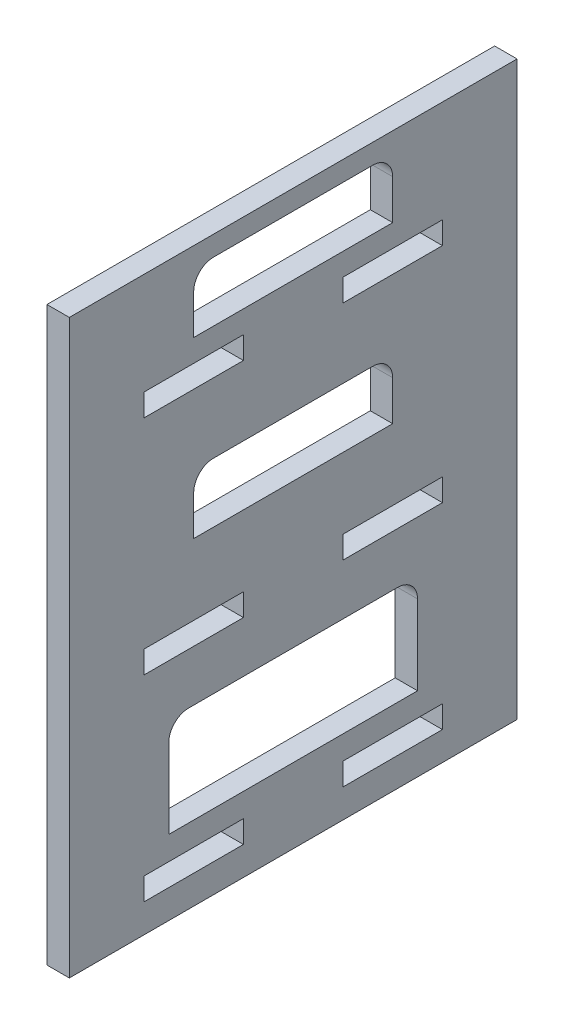
from build123d import *

# Parameters (mm, degrees)
SKETCH1_W           = 40
SKETCH1_H           = 12
SKETCH1_W_2         = 50
SKETCH1_H_2         = 20
SKETCH1_W_3         = 20
SKETCH1_H_3         = 4.5
BOSS_EXTRUDE1_DEPTH = 4.5
FILLET1_R           = 4


with BuildPart() as part:
    # Sketch1 → Boss-Extrude1 (new body)
    with BuildSketch(Plane(origin=(0, 0, 0), x_dir=(0, 0, -1), z_dir=(1, 0, 0))):
        Polygon((0, 0), (0, 5), (0, 45), (0, 50), (0, 90), (0, 95), (0, 115), (90, 115), (90, 45), (90, 5), (90, 0), align=None)
        with Locations((45, 105)):
            Rectangle(SKETCH1_W, SKETCH1_H, mode=Mode.SUBTRACT)
        with Locations((45, 70)):
            Rectangle(SKETCH1_W, SKETCH1_H, mode=Mode.SUBTRACT)
        with Locations((45, 25)):
            Rectangle(SKETCH1_W_2, SKETCH1_H_2, mode=Mode.SUBTRACT)
        with Locations((65, 92.25)):
            Rectangle(SKETCH1_W_3, SKETCH1_H_3, mode=Mode.SUBTRACT)
        with Locations((25, 92.25)):
            Rectangle(SKETCH1_W_3, SKETCH1_H_3, mode=Mode.SUBTRACT)
        with Locations((65, 47.5)):
            Rectangle(SKETCH1_W_3, SKETCH1_H_3, mode=Mode.SUBTRACT)
        with Locations((25, 47.5)):
            Rectangle(SKETCH1_W_3, SKETCH1_H_3, mode=Mode.SUBTRACT)
        with Locations((65, 8)):
            Rectangle(SKETCH1_W_3, SKETCH1_H_3, mode=Mode.SUBTRACT)
        with Locations((25, 8)):
            Rectangle(SKETCH1_W_3, SKETCH1_H_3, mode=Mode.SUBTRACT)
    extrude(amount=BOSS_EXTRUDE1_DEPTH)

    # Fillet1
    fillet1_edges = [part.edges().sort_by_distance(p)[0] for p in [
        (2.25, 76, -65),
        (2.25, 76, -25),
        (2.25, 35, -70),
        (2.25, 35, -20),
        (2.25, 111, -65),
        (2.25, 111, -25),
    ]]
    fillet(fillet1_edges, radius=FILLET1_R)


solid = part.part
